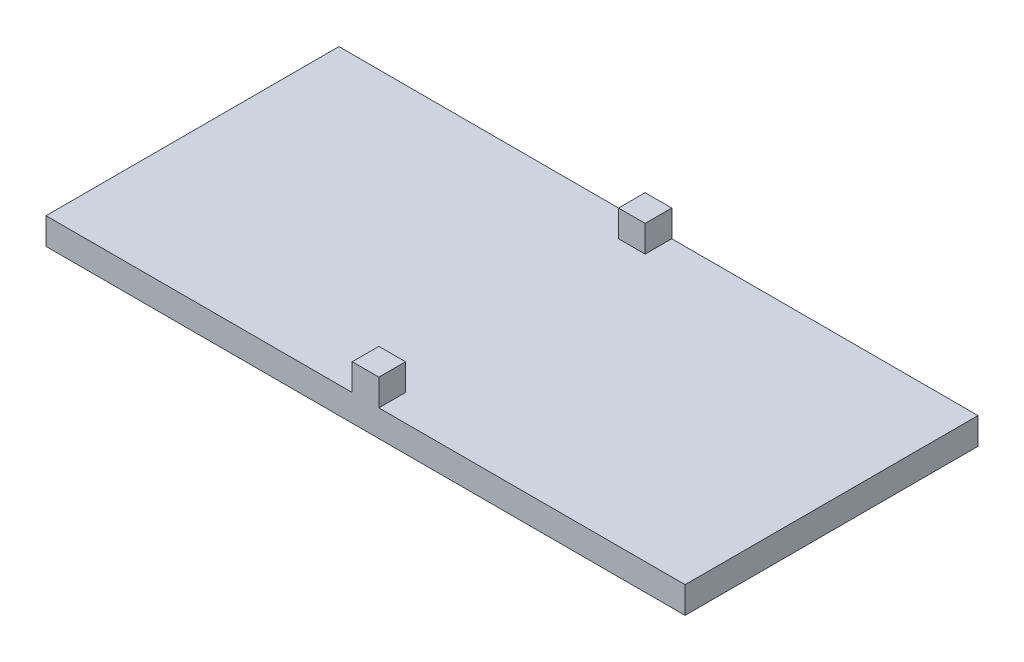
from build123d import *

# Parameters (mm, degrees)
ESBO_O1_W                = 240
ESBO_O1_H                = 110
RESSALTO_EXTRUS_O1_DEPTH = 10
ESBO_O2_W                = 10
ESBO_O2_H                = 10
RESSALTO_EXTRUS_O2_DEPTH = 10


with BuildPart() as part:
    # Esboço1 → Ressalto-extrusão1 (new body)
    with BuildSketch(Plane(origin=(0, 0, 0), x_dir=(1, 0, 0), z_dir=(0, 1, 0))):
        with Locations((88.671510894, 29.610744501)):
            Rectangle(ESBO_O1_W, ESBO_O1_H)
    extrude(amount=RESSALTO_EXTRUS_O1_DEPTH)

    # Esboço2 → Ressalto-extrusão2 (add)
    with BuildSketch(Plane(origin=(0, 10, 0), x_dir=(1, 0, 0), z_dir=(0, 1, 0))):
        with Locations((88.671510894, -20.389255499)):
            Rectangle(ESBO_O2_W, ESBO_O2_H)
        with Locations((88.671510894, 79.610744501)):
            Rectangle(ESBO_O2_W, ESBO_O2_H)
    extrude(amount=RESSALTO_EXTRUS_O2_DEPTH)


solid = part.part
